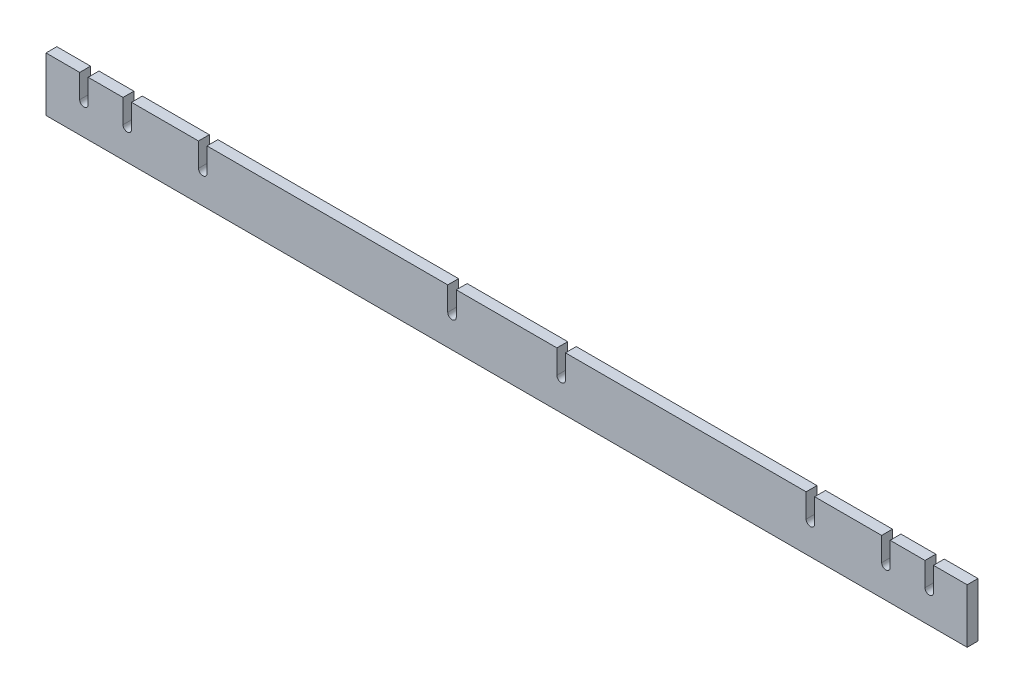
from build123d import *

# Parameters (mm, degrees)
SKETCH1_W          = 1079.5
SKETCH1_H          = 63.5
EXTRUDE1_DEPTH     = 12.7
CUT_EXTRUDE1_DEPTH = 13.7
CUT_EXTRUDE2_DEPTH = 20.32


with BuildPart() as part:
    # Sketch1 → Extrude1 (new body)
    with BuildSketch(Plane.XY):
        with Locations((0, 996.95)):
            Rectangle(SKETCH1_W, SKETCH1_H)
    extrude(amount=EXTRUDE1_DEPTH)

    # Sketch4 → Cut-Extrude1 (cut, through all)
    with BuildSketch(Plane(origin=(0, 0, 0), x_dir=(-1, 0, 0), z_dir=(0, 0, -1))):
        with BuildLine():
            Line((-68.95, 1028.7), (-68.95, 1000.9))
            ThreePointArc((-68.95, 1000.9), (-63.95, 995.9), (-58.95, 1000.9))
            Line((-58.95, 1000.9), (-58.95, 1028.7))
            Line((-58.95, 1028.7), (-68.95, 1028.7))
        make_face()
        with BuildLine():
            Line((-351.05, 1028.7), (-361.05, 1028.7))
            Line((-361.05, 1028.7), (-361.05, 1000.9))
            ThreePointArc((-361.05, 1000.9), (-356.05, 995.9), (-351.05, 1000.9))
            Line((-351.05, 1000.9), (-351.05, 1028.7))
        make_face()
        with BuildLine():
            Line((58.95, 1028.7), (58.95, 1000.9))
            ThreePointArc((58.95, 1000.9), (63.95, 995.9), (68.95, 1000.9))
            Line((68.95, 1000.9), (68.95, 1028.7))
            Line((68.95, 1028.7), (58.95, 1028.7))
        make_face()
        with BuildLine():
            Line((351.05, 1028.7), (351.05, 1000.9))
            ThreePointArc((351.05, 1000.9), (356.05, 995.9), (361.05, 1000.9))
            Line((361.05, 1000.9), (361.05, 1028.7))
            Line((361.05, 1028.7), (351.05, 1028.7))
        make_face()
    extrude(amount=-CUT_EXTRUDE1_DEPTH, mode=Mode.SUBTRACT)

    # Sketch6 → Cut-Extrude2 (cut)
    with BuildSketch(Plane(origin=(0, 0, 0), x_dir=(-1, 0, 0), z_dir=(0, 0, -1))):
        with BuildLine():
            Line((-449.453, 1028.7), (-439.547, 1028.7))
            Line((-439.547, 1028.7), (-439.547, 1001.014))
            ThreePointArc((-439.547, 1001.014), (-444.5, 996.061), (-449.453, 1001.014))
            Line((-449.453, 1001.014), (-449.453, 1028.7))
        make_face()
        with BuildLine():
            Line((439.547, 1028.7), (449.453, 1028.7))
            Line((449.453, 1028.7), (449.453, 1001.014))
            ThreePointArc((449.453, 1001.014), (444.5, 996.061), (439.547, 1001.014))
            Line((439.547, 1001.014), (439.547, 1028.7))
        make_face()
        with BuildLine():
            Line((490.347, 1001.014), (490.347, 1028.7))
            Line((490.347, 1028.7), (500.253, 1028.7))
            Line((500.253, 1028.7), (500.253, 1001.014))
            ThreePointArc((500.253, 1001.014), (495.3, 996.061), (490.347, 1001.014))
        make_face()
        with BuildLine():
            Line((-490.347, 1001.014), (-490.347, 1028.7))
            Line((-490.347, 1028.7), (-500.253, 1028.7))
            Line((-500.253, 1028.7), (-500.253, 1001.014))
            ThreePointArc((-500.253, 1001.014), (-495.3, 996.061), (-490.347, 1001.014))
        make_face()
    extrude(amount=-CUT_EXTRUDE2_DEPTH, mode=Mode.SUBTRACT)


solid = part.part
